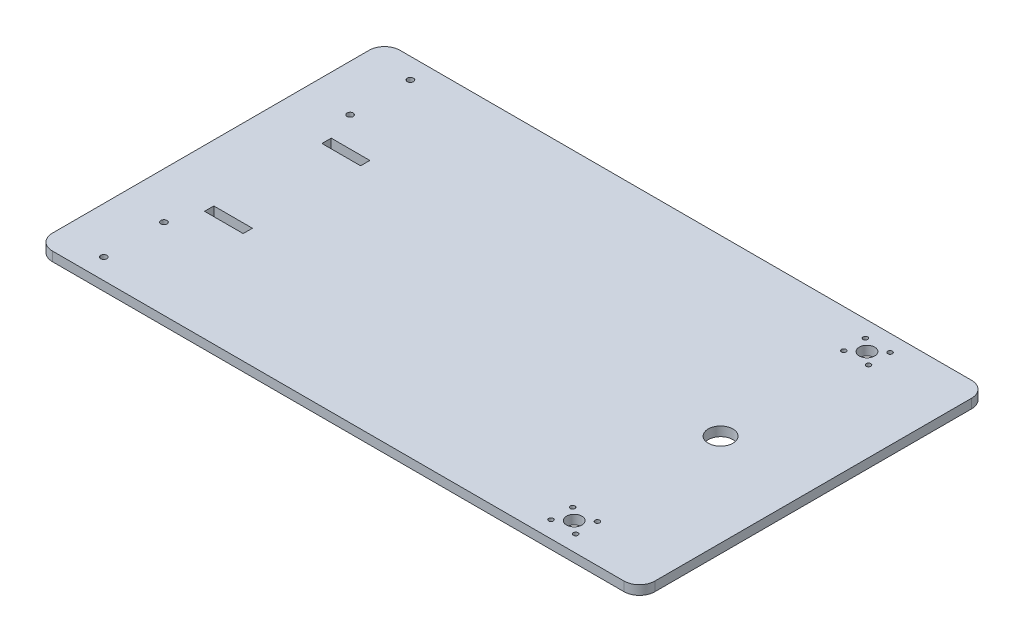
from build123d import *

# Parameters (mm, degrees)
SKETCH1_R           = 8
SKETCH1_R_2         = 5
SKETCH1_R_3         = 1.5
SKETCH1_R_4         = 2
SKETCH1_W           = 25
SKETCH1_H           = 6
BOSS_EXTRUDE1_DEPTH = 6


with BuildPart() as part:
    # Sketch1 → Boss-Extrude1 (new body)
    with BuildSketch(Plane(origin=(0, 0, 0), x_dir=(1, 0, 0), z_dir=(0, 1, 0))):
        with BuildLine():
            Line((-185, 112.5), (185, 112.5))
            ThreePointArc((185, 112.5), (192.071067812, 109.571067812), (195, 102.5))
            Line((195, 102.5), (195, -102.5))
            ThreePointArc((195, -102.5), (192.071067812, -109.571067812), (185, -112.5))
            Line((185, -112.5), (-185, -112.5))
            ThreePointArc((-185, -112.5), (-192.071067812, -109.571067812), (-195, -102.5))
            Line((-195, -102.5), (-195, 102.5))
            ThreePointArc((-195, 102.5), (-192.071067812, 109.571067812), (-185, 112.5))
        make_face()
        with Locations((135, 0)):
            Circle(SKETCH1_R, mode=Mode.SUBTRACT)
        with Locations((135, -94.75)):
            Circle(SKETCH1_R_2, mode=Mode.SUBTRACT)
        with Locations((143, -87.75)):
            Circle(SKETCH1_R_3, mode=Mode.SUBTRACT)
        with Locations((143, -101.75)):
            Circle(SKETCH1_R_3, mode=Mode.SUBTRACT)
        with Locations((127, -87.75)):
            Circle(SKETCH1_R_3, mode=Mode.SUBTRACT)
        with Locations((127, -101.75)):
            Circle(SKETCH1_R_3, mode=Mode.SUBTRACT)
        with Locations((143, 101.75)):
            Circle(SKETCH1_R_3, mode=Mode.SUBTRACT)
        with Locations((143, 87.75)):
            Circle(SKETCH1_R_3, mode=Mode.SUBTRACT)
        with Locations((127, 101.75)):
            Circle(SKETCH1_R_3, mode=Mode.SUBTRACT)
        with Locations((127, 87.75)):
            Circle(SKETCH1_R_3, mode=Mode.SUBTRACT)
        with Locations((135, 94.75)):
            Circle(SKETCH1_R_2, mode=Mode.SUBTRACT)
        with Locations((-165, -60.25)):
            Circle(SKETCH1_R_4, mode=Mode.SUBTRACT)
        with Locations((-165, -99.25)):
            Circle(SKETCH1_R_4, mode=Mode.SUBTRACT)
        with Locations((-165, 60.25)):
            Circle(SKETCH1_R_4, mode=Mode.SUBTRACT)
        with Locations((-165, 99.25)):
            Circle(SKETCH1_R_4, mode=Mode.SUBTRACT)
        with Locations((-145.5, 38)):
            Rectangle(SKETCH1_W, SKETCH1_H, mode=Mode.SUBTRACT)
        with Locations((-145.5, -38)):
            Rectangle(SKETCH1_W, SKETCH1_H, mode=Mode.SUBTRACT)
    extrude(amount=BOSS_EXTRUDE1_DEPTH)


solid = part.part
